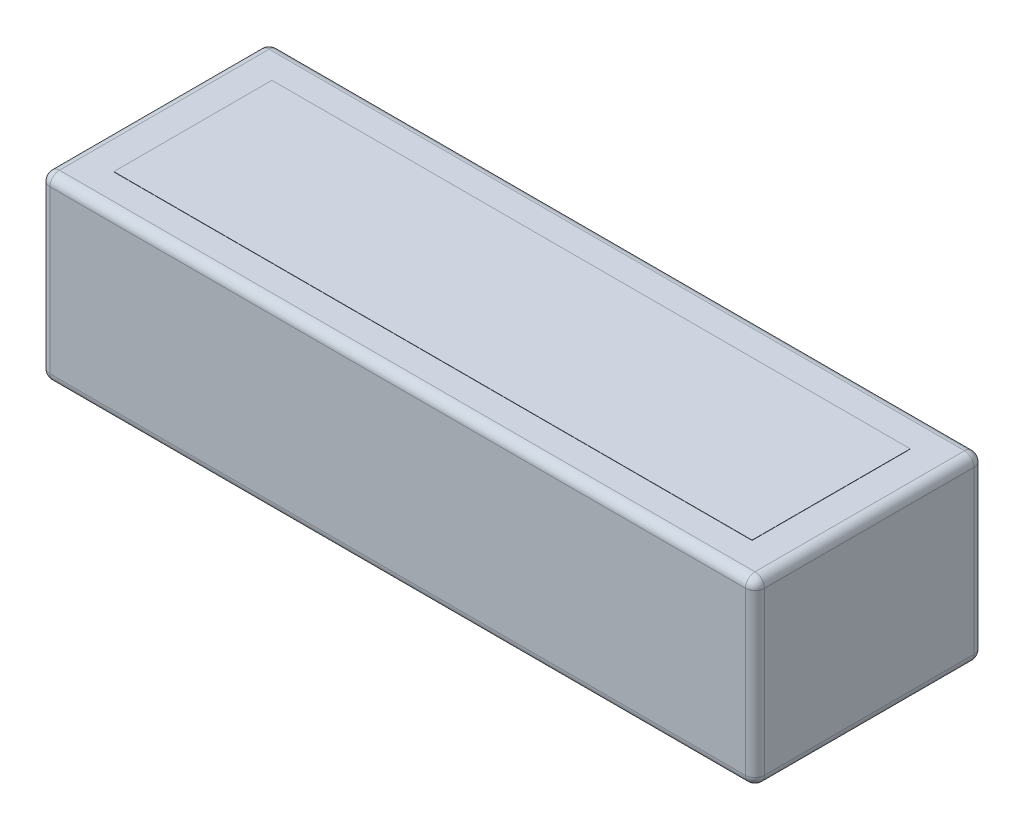
from build123d import *

# Parameters (mm, degrees)
SKETCH1_W           = 150
SKETCH1_H           = 48
BOSS_EXTRUDE1_DEPTH = 38
FILLET1_R           = 2
FILLET2_R           = 2
SKETCH3_W           = 133.991649932
SKETCH3_H           = 33.197482774
BOSS_EXTRUDE2_DEPTH = 0.05


with BuildPart() as part:
    # Sketch1 → Boss-Extrude1 (new body)
    with BuildSketch(Plane(origin=(0, 0, 0), x_dir=(1, 0, 0), z_dir=(0, 1, 0))):
        Rectangle(SKETCH1_W, SKETCH1_H)
    extrude(amount=BOSS_EXTRUDE1_DEPTH)

    # Fillet1
    fillet1_edges = [part.edges().sort_by_distance(p)[0] for p in [
        (75, 19, 24),
        (-75, 19, 24),
        (-75, 19, -24),
        (75, 19, -24),
    ]]
    fillet(fillet1_edges, radius=FILLET1_R)

    # Fillet2
    fillet2_edges = [part.edges().sort_by_distance(p)[0] for p in [
        (0, 0, -24),
        (0, 38, -24),
        (75, 0, 0),
        (0, 0, 24),
        (-75, 0, 0),
        (-74.414213562, 0, 23.414213562),
        (-74.414213562, 0, -23.414213562),
        (74.414213562, 0, 23.414213562),
        (74.414213562, 0, -23.414213562),
        (75, 38, 0),
        (-75, 38, 0),
        (0, 38, 24),
        (-74.414213562, 38, 23.414213562),
        (-74.414213562, 38, -23.414213562),
        (74.414213562, 38, 23.414213562),
        (74.414213562, 38, -23.414213562),
    ]]
    fillet(fillet2_edges, radius=FILLET2_R)

    # Sketch3 → Boss-Extrude2 (add)
    with BuildSketch(Plane(origin=(0, 38, 0), x_dir=(1, 0, 0), z_dir=(0, 1, 0))):
        Rectangle(SKETCH3_W, SKETCH3_H)
    extrude(amount=BOSS_EXTRUDE2_DEPTH)


solid = part.part
